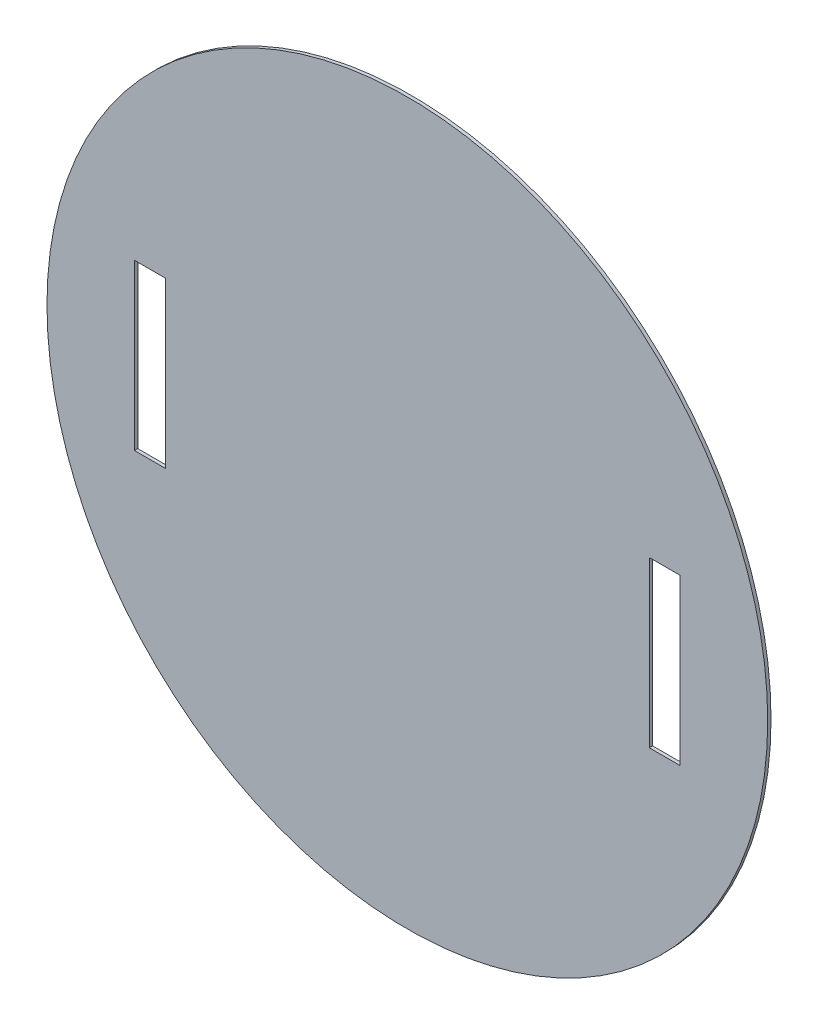
from build123d import *

# Parameters (mm, degrees)
SKETCH1_R           = 175
BOSS_EXTRUDE1_DEPTH = 1.6
SKETCH2_W           = 15
SKETCH2_H           = 80
CUT_EXTRUDE1_DEPTH  = 2.6


with BuildPart() as part:
    # Sketch1 → Boss-Extrude1 (new body)
    with BuildSketch(Plane.XY):
        Circle(SKETCH1_R)
    extrude(amount=BOSS_EXTRUDE1_DEPTH)

    # Sketch2 → Cut-Extrude1 (cut, through all)
    with BuildSketch(Plane.XY.offset(1.6)):
        with Locations((-125, 0)):
            Rectangle(SKETCH2_W, SKETCH2_H)
        with Locations((125, 0)):
            Rectangle(SKETCH2_W, SKETCH2_H)
    extrude(amount=-CUT_EXTRUDE1_DEPTH, mode=Mode.SUBTRACT)


solid = part.part
